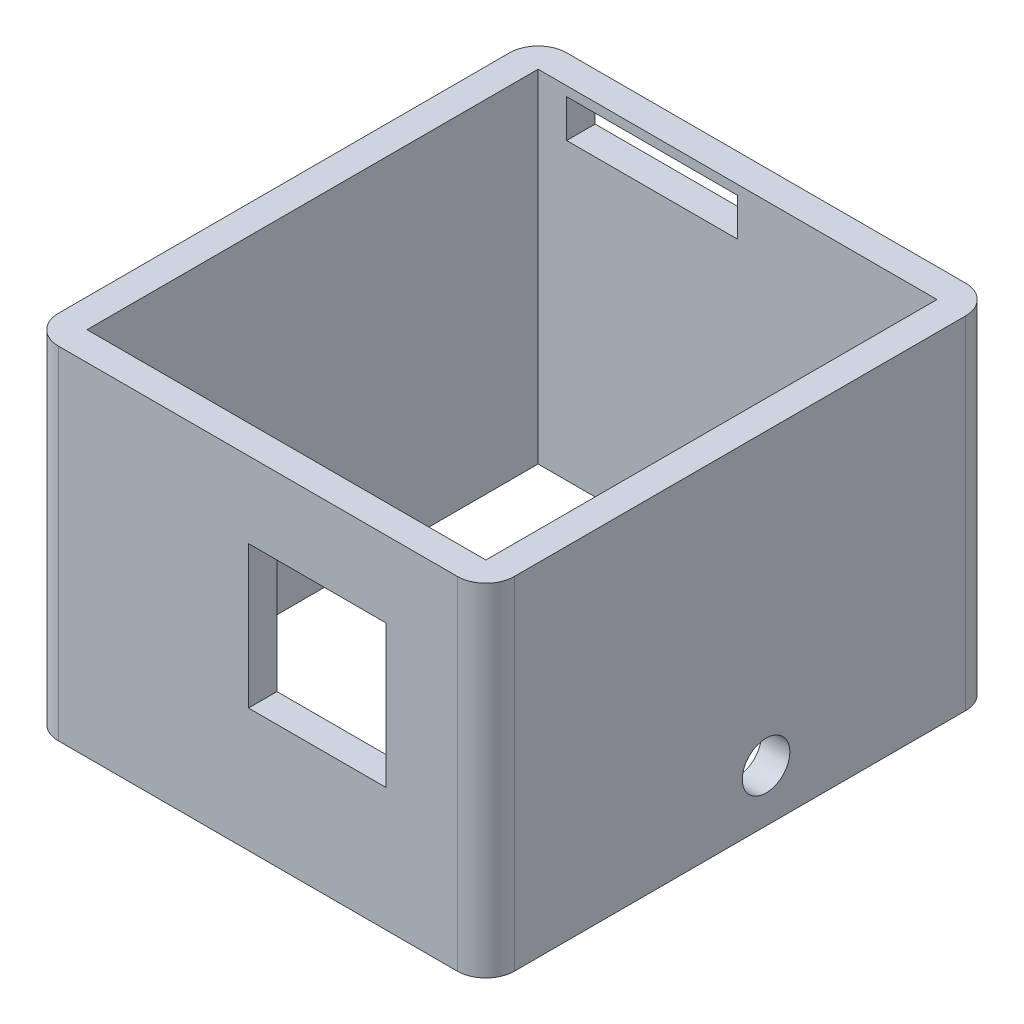
from build123d import *

# Parameters (mm, degrees)
SKETCH1_W           = 48
SKETCH1_H           = 53.5
SKETCH1_W_2         = 42
SKETCH1_H_2         = 47.5
BOSS_EXTRUDE1_DEPTH = 36
SKETCH2_R           = 2.5
CUT_EXTRUDE1_DEPTH  = 9
SKETCH4_W           = 14.5
SKETCH4_H           = 15
CUT_EXTRUDE2_DEPTH  = 15
SKETCH6_W           = 18
SKETCH6_H           = 4
CUT_EXTRUDE3_DEPTH  = 15
FILLET1_R           = 3


with BuildPart() as part:
    # Sketch1 → Boss-Extrude1 (new body)
    with BuildSketch(Plane(origin=(0, 0, 0), x_dir=(1, 0, 0), z_dir=(0, 1, 0))):
        Rectangle(SKETCH1_W, SKETCH1_H)
        Rectangle(SKETCH1_W_2, SKETCH1_H_2, mode=Mode.SUBTRACT)
    extrude(amount=BOSS_EXTRUDE1_DEPTH)

    # Sketch2 → Cut-Extrude1 (cut)
    with BuildSketch(Plane(origin=(21, 0, 0), x_dir=(0, 0, -1), z_dir=(1, 0, 0))):
        with Locations((2.75, 5.5)):
            Circle(SKETCH2_R)
    extrude(amount=CUT_EXTRUDE1_DEPTH, mode=Mode.SUBTRACT)

    # Sketch4 → Cut-Extrude2 (cut)
    with BuildSketch(Plane.XY.offset(23.75)):
        with Locations((6.25, 20.5)):
            Rectangle(SKETCH4_W, SKETCH4_H)
    extrude(amount=CUT_EXTRUDE2_DEPTH, mode=Mode.SUBTRACT)

    # Sketch6 → Cut-Extrude3 (cut)
    with BuildSketch(Plane.XY.offset(-23.75)):
        with Locations((-9, 33)):
            Rectangle(SKETCH6_W, SKETCH6_H)
    extrude(amount=-CUT_EXTRUDE3_DEPTH, mode=Mode.SUBTRACT)

    # Fillet1
    fillet1_edges = [part.edges().sort_by_distance(p)[0] for p in [
        (24, 18, 26.75),
        (-24, 18, 26.75),
        (-24, 18, -26.75),
        (24, 18, -26.75),
    ]]
    fillet(fillet1_edges, radius=FILLET1_R)


solid = part.part
